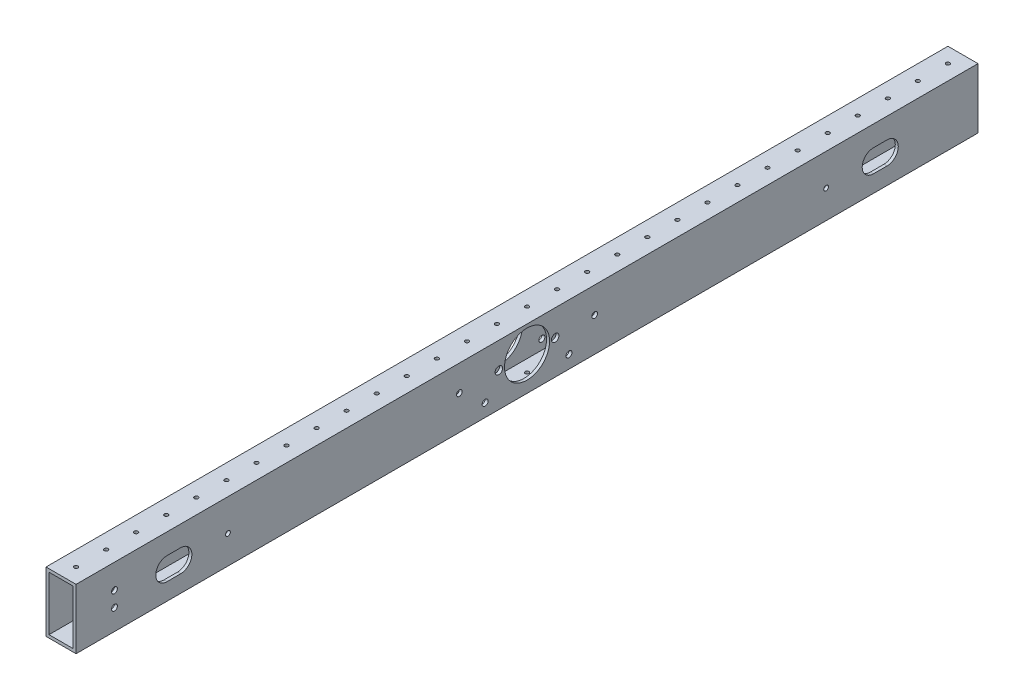
from build123d import *

# Parameters (mm, degrees)
SKETCH1_W           = 25.4
SKETCH1_H           = 50.8
SKETCH1_W_2         = 20.32
SKETCH1_H_2         = 45.72
EXTRUDE_THIN1_DEPTH = 381
SKETCH3_R           = 1.5875
CUT_EXTRUDE2_DEPTH  = 51.8
LPATTERN1_COUNT     = 220
LPATTERN1_PITCH     = 25.4
SKETCH6_R           = 19.05
SKETCH6_R_2         = 3.175
CUT_EXTRUDE5_DEPTH  = 26.4
SKETCH4_R           = 9.525
CUT_EXTRUDE3_DEPTH  = 26.4
CUT_EXTRUDE6_START  = -22.86
SKETCH7_R           = 6.35
CUT_EXTRUDE6_DEPTH  = 2.54
SKETCH8_R           = 2.5273
CUT_EXTRUDE7_DEPTH  = 26.4
SKETCH9_R           = 2.0193
CUT_EXTRUDE8_DEPTH  = 26.4
SKETCH10_R          = 2.4892
CUT_EXTRUDE9_DEPTH  = 26.4
SKETCH11_R          = 2.413
CUT_EXTRUDE10_DEPTH = 26.4


with BuildPart() as part:
    # Sketch1 → Extrude-Thin1 (new body, symmetric)
    with BuildSketch(Plane.XY):
        with Locations((12.7, 25.4)):
            Rectangle(SKETCH1_W, SKETCH1_H)
        with Locations((12.7, 25.4)):
            Rectangle(SKETCH1_W_2, SKETCH1_H_2, mode=Mode.SUBTRACT)
    extrude(amount=EXTRUDE_THIN1_DEPTH, both=True)

    # Sketch3 → Cut-Extrude2 (cut, through all)
    with BuildSketch(Plane(origin=(0, 50.8, 0), x_dir=(1, 0, 0), z_dir=(0, 1, 0))):
        with Locations((12.7, -368.3)):
            Circle(SKETCH3_R)
    cut_extrude2 = extrude(amount=-CUT_EXTRUDE2_DEPTH, mode=Mode.SUBTRACT)

    # LPattern1: Cut-Extrude2 ×220
    with Locations(*[(0, 0, -i * LPATTERN1_PITCH) for i in range(1, LPATTERN1_COUNT)]):
        add(cut_extrude2, mode=Mode.SUBTRACT)

    # Sketch6 → Cut-Extrude5 (cut, through all)
    with BuildSketch(Plane(origin=(25.4, 0, 0), x_dir=(0, 0, -1), z_dir=(1, 0, 0))):
        with Locations((0, 28.7655)):
            Circle(SKETCH6_R)
        with Locations((23.8125, 28.7655)):
            Circle(SKETCH6_R_2)
        with Locations((-23.8125, 28.7655)):
            Circle(SKETCH6_R_2)
    extrude(amount=-CUT_EXTRUDE5_DEPTH, mode=Mode.SUBTRACT)

    # Sketch4 → Cut-Extrude3 (cut, through all)
    with BuildSketch(Plane(origin=(25.4, 0, 0), x_dir=(0, 0, -1), z_dir=(1, 0, 0))):
        with Locations((295.234514267, 23.876)):
            Circle(SKETCH4_R)
        with BuildLine():
            Line((304.124514267, 33.401), (295.234514267, 33.401))
            ThreePointArc((295.234514267, 33.401), (301.969706358, 30.611192091), (304.759514267, 23.876))
            ThreePointArc((304.759514267, 23.876), (301.969706356, 17.140807907), (295.234514261, 14.351))
            Line((295.234514261, 14.351), (304.124514267, 14.351))
            ThreePointArc((304.124514267, 14.351), (313.649514267, 23.876), (304.124514267, 33.401))
        make_face()
        with BuildLine():
            Line((295.234514267, 33.401), (292.694514267, 33.401))
            ThreePointArc((292.694514267, 33.401), (283.169514267, 23.876), (292.694514267, 14.351))
            Line((292.694514267, 14.351), (295.234514261, 14.351))
            ThreePointArc((295.234514261, 14.351), (285.709514267, 23.876000003), (295.234514267, 33.401))
        make_face()
    cut_extrude3 = extrude(amount=-CUT_EXTRUDE3_DEPTH, mode=Mode.SUBTRACT)

    # Mirror1: Cut-Extrude3 across plane
    add(cut_extrude3.mirror(Plane.XY), mode=Mode.SUBTRACT)

    # Sketch7 → Cut-Extrude6 (cut)
    with BuildSketch(Plane(origin=(25.4, 0, 0), x_dir=(0, 0, -1), z_dir=(1, 0, 0)).offset(CUT_EXTRUDE6_START)):
        with Locations((57.15, 28.7655)):
            Circle(SKETCH7_R)
        with Locations((-57.15, 28.7655)):
            Circle(SKETCH7_R)
    extrude(amount=-CUT_EXTRUDE6_DEPTH, mode=Mode.SUBTRACT)

    # Sketch8 → Cut-Extrude7 (cut, through all)
    with BuildSketch(Plane(origin=(25.4, 0, 0), x_dir=(0, 0, -1), z_dir=(1, 0, 0))):
        with Locations((-35.41150672, 10.9347)):
            Circle(SKETCH8_R)
        with Locations((35.41150672, 10.9347)):
            Circle(SKETCH8_R)
    extrude(amount=-CUT_EXTRUDE7_DEPTH, mode=Mode.SUBTRACT)

    # Sketch9 → Cut-Extrude8 (cut, through all)
    with BuildSketch(Plane.ZY):
        with Locations((252.689514267, 23.876)):
            Circle(SKETCH9_R)
    cut_extrude8 = extrude(amount=-CUT_EXTRUDE8_DEPTH, mode=Mode.SUBTRACT)

    # Mirror2: Cut-Extrude8 across plane
    add(cut_extrude8.mirror(Plane.XY), mode=Mode.SUBTRACT)

    # Sketch10 → Cut-Extrude9 (cut, through all)
    with BuildSketch(Plane.ZY):
        with Locations((348.574514267, 30.226)):
            Circle(SKETCH10_R)
        with Locations((348.574514267, 17.526)):
            Circle(SKETCH10_R)
    extrude(amount=-CUT_EXTRUDE9_DEPTH, mode=Mode.SUBTRACT)

    # Sketch11 → Cut-Extrude10 (cut, through all)
    with BuildSketch(Plane.ZY):
        with Locations((-57.15, 28.7655)):
            Circle(SKETCH11_R)
        with Locations((57.15, 28.7655)):
            Circle(SKETCH11_R)
    extrude(amount=-CUT_EXTRUDE10_DEPTH, mode=Mode.SUBTRACT)


solid = part.part
